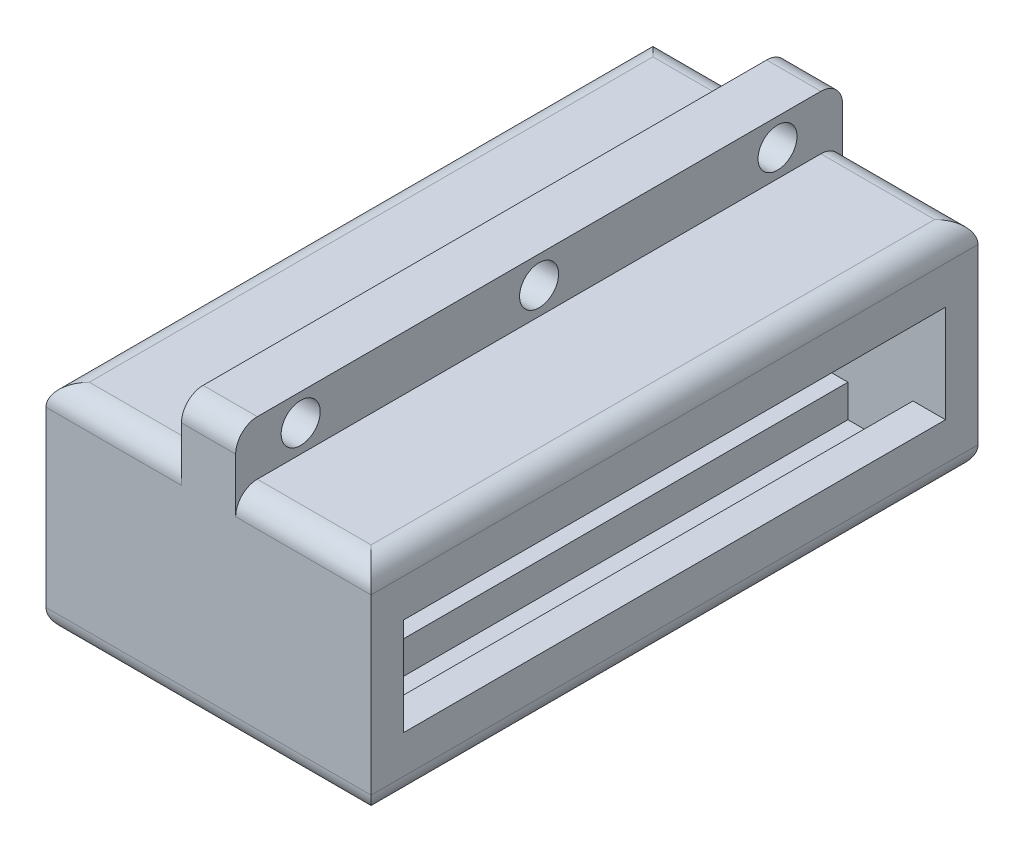
from build123d import *

# Parameters (mm, degrees)
BOSS_EXTRUDE1_DEPTH = 28
CUT_EXTRUDE3_START  = -1.5
CUT_EXTRUDE3_DEPTH  = 25
SKETCH3_R           = 0.9
CUT_EXTRUDE2_DEPTH  = 2.5
FILLET2_R           = 1


with BuildPart() as part:
    # Sketch1 → Boss-Extrude1 (new body)
    with BuildSketch(Plane.XY):
        Polygon((0, 0), (15, 0), (15, 10), (8.75, 10), (8.75, 12.5), (6.25, 12.5), (6.25, 10), (0, 10), align=None)
    extrude(amount=-BOSS_EXTRUDE1_DEPTH)

    # Sketch4 → Cut-Extrude3 (cut)
    with BuildSketch(Plane.XY.offset(CUT_EXTRUDE3_START)):
        Polygon((10.5, 8), (10.5, 9.5), (13.5, 9.5), (13.5, 7.25), (15, 7.25), (15, 2.75), (13.5, 2.75), (13.5, 0.5), (10.5, 0.5), (10.5, 2), (9.75, 2), (9.75, 0), (5.25, 0), (5.25, 2), (4.5, 2), (4.5, 0.5), (1.5, 0.5), (1.5, 2.75), (0, 2.75), (0, 7.25), (1.5, 7.25), (1.5, 9.5), (4.5, 9.5), (4.5, 8), align=None)
    extrude(amount=-CUT_EXTRUDE3_DEPTH, mode=Mode.SUBTRACT)

    # Sketch3 → Cut-Extrude2 (cut)
    with BuildSketch(Plane(origin=(8.75, 0, 0), x_dir=(0, 0, -1), z_dir=(1, 0, 0))):
        with Locations((14, 11.25)):
            Circle(SKETCH3_R)
        with Locations((3, 11.25)):
            Circle(SKETCH3_R)
        with Locations((25, 11.25)):
            Circle(SKETCH3_R)
    extrude(amount=-CUT_EXTRUDE2_DEPTH, mode=Mode.SUBTRACT)

    # Fillet2
    fillet2_edges = [part.edges().sort_by_distance(p)[0] for p in [
        (7.5, 0, 0),
        (11.875, 10, -28),
        (0, 10, -14),
        (15, 10, -14),
        (15, 0, -14),
        (0, 0, -14),
        (7.5, 12.5, -28),
        (3.125, 10, -28),
        (7.5, 0, -28),
        (3.125, 10, 0),
        (7.5, 12.5, 0),
        (11.875, 10, 0),
    ]]
    fillet(fillet2_edges, radius=FILLET2_R)


solid = part.part
